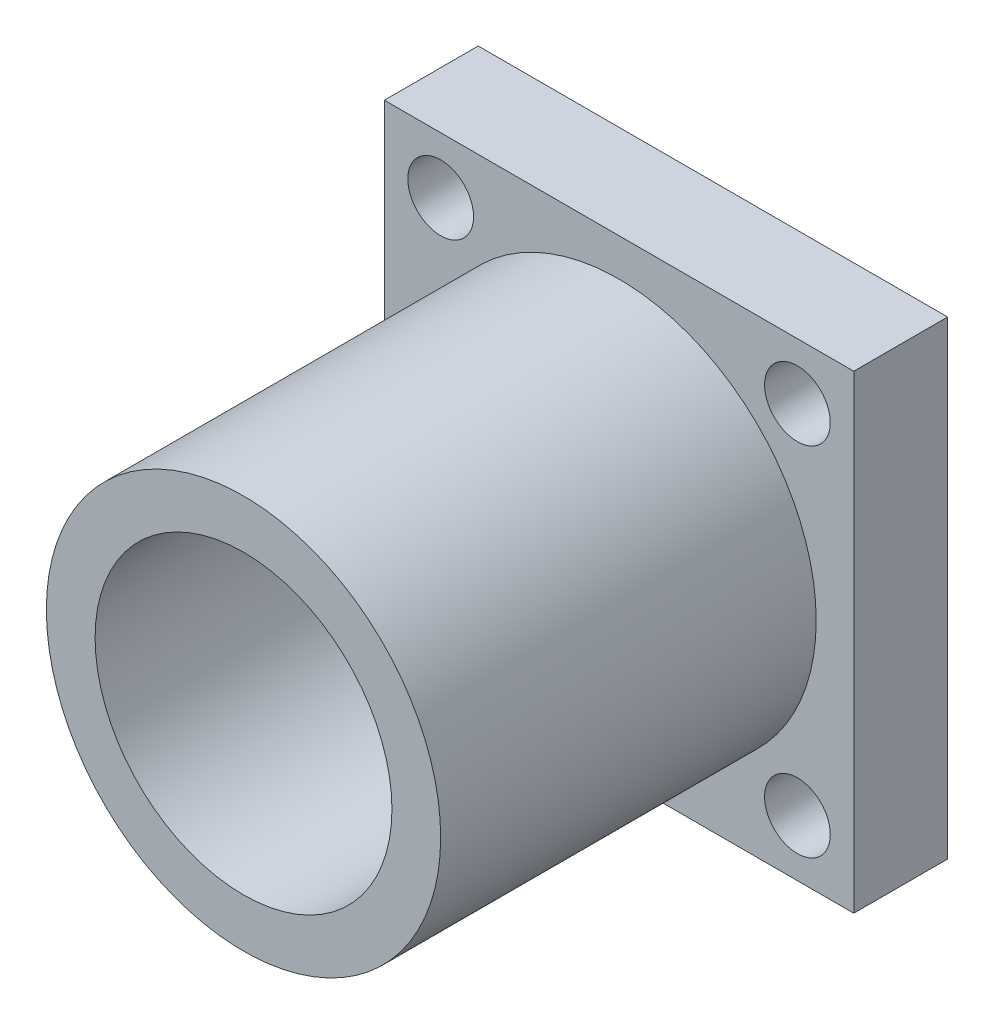
from build123d import *

# Parameters (mm, degrees)
SKETCH_1_W          = 25
SKETCH_1_H          = 25
SKETCH_1_R          = 1.75
EXTRUDE_1_DEPTH     = 5
SKETCH_2_R          = 7.905
CUT_EXTRUDE_1_DEPTH = 5
SKETCH_3_R          = 10.5
SKETCH_3_R_2        = 7.905
EXTRUDE_2_DEPTH     = 20


with BuildPart() as part:
    # 草图1 → 凸台-拉伸1 (new body)
    with BuildSketch(Plane.XY):
        Rectangle(SKETCH_1_W, SKETCH_1_H)
        with Locations((-9.5, 9.5)):
            Circle(SKETCH_1_R, mode=Mode.SUBTRACT)
        with Locations((-9.5, -9.5)):
            Circle(SKETCH_1_R, mode=Mode.SUBTRACT)
        with Locations((9.5, -9.5)):
            Circle(SKETCH_1_R, mode=Mode.SUBTRACT)
        with Locations((9.5, 9.5)):
            Circle(SKETCH_1_R, mode=Mode.SUBTRACT)
    extrude(amount=EXTRUDE_1_DEPTH)

    # 草图2 → 切除-拉伸1 (cut)
    with BuildSketch(Plane.XY.offset(5)):
        Circle(SKETCH_2_R)
    extrude(amount=-CUT_EXTRUDE_1_DEPTH, mode=Mode.SUBTRACT)

    # 草图3 → 凸台-拉伸2 (add)
    with BuildSketch(Plane.XY.offset(5)):
        Circle(SKETCH_3_R)
        Circle(SKETCH_3_R_2, mode=Mode.SUBTRACT)
    extrude(amount=EXTRUDE_2_DEPTH)


solid = part.part
